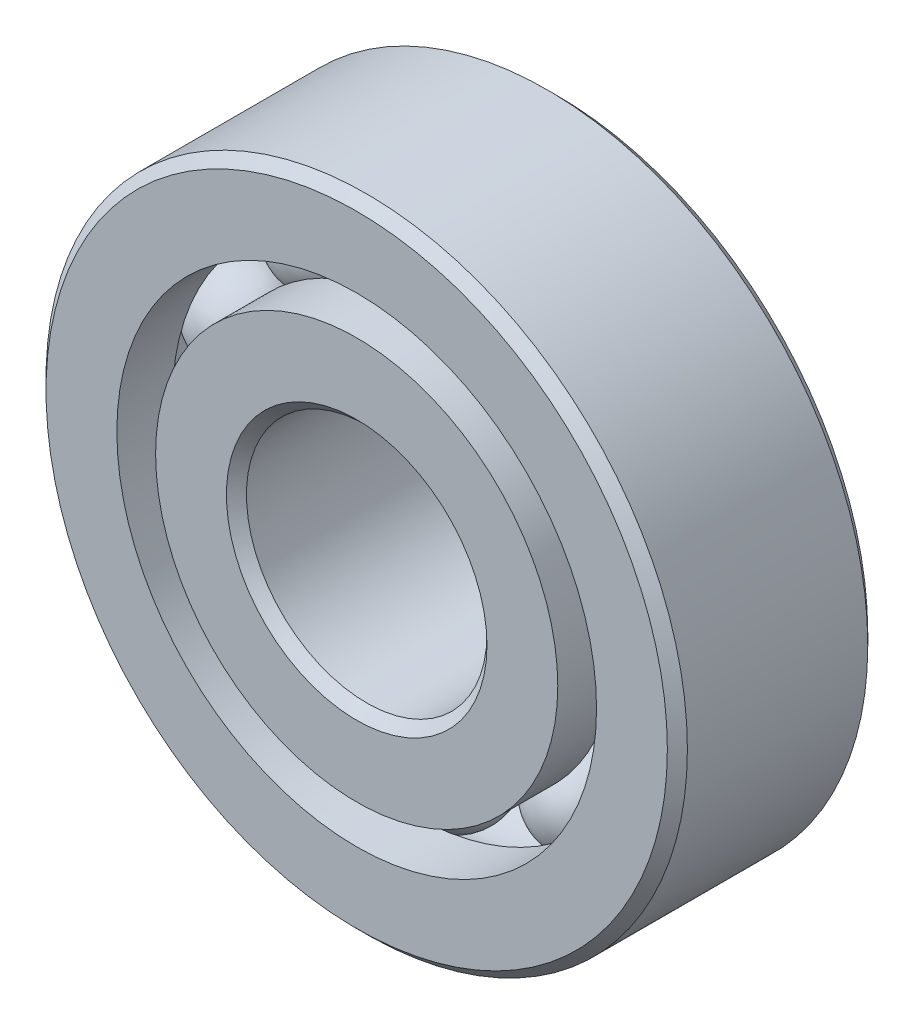
from build123d import *

# Parameters (mm, degrees)
CIRPATTERN1_COUNT = 10


with BuildPart() as part:
    # Sketch1 → Revolve1 (revolve)
    with BuildSketch(Plane(origin=(0, 0, 0), x_dir=(0, 0, -1), z_dir=(1, 0, 0))):
        with BuildLine():
            Line((1.7859375, 6.35), (-1.7859375, 6.35))
            Line((-1.7859375, 6.35), (-1.984375, 6.1515625))
            Line((-1.984375, 6.1515625), (-1.984375, 4.749416209))
            Line((-1.984375, 4.749416209), (-0.881944444, 4.749416209))
            ThreePointArc((-0.881944444, 4.749416209), (0, 5.327457467), (0.881944444, 4.749416209))
            Line((0.881944444, 4.749416209), (1.984375, 4.749416209))
            Line((1.984375, 4.749416209), (1.984375, 6.1515625))
            Line((1.984375, 6.1515625), (1.7859375, 6.35))
        make_face()
    revolve(axis=Axis((0, 0, 1.984375), (0, 0, -1)))


with BuildPart() as body_2:
    # Sketch3 → Revolve3 (revolve)
    with BuildSketch(Plane(origin=(0, 0, 0), x_dir=(0, 0, -1), z_dir=(1, 0, 0))):
        with BuildLine():
            Line((-1.984375, 3.981833791), (-0.881944444, 3.981833791))
            ThreePointArc((-0.881944444, 3.981833791), (0, 3.403792533), (0.881944444, 3.981833791))
            Line((0.881944444, 3.981833791), (1.984375, 3.981833791))
            Line((1.984375, 3.981833791), (1.984375, 2.5796875))
            Line((1.984375, 2.5796875), (1.7859375, 2.38125))
            Line((1.7859375, 2.38125), (-1.7859375, 2.38125))
            Line((-1.7859375, 2.38125), (-1.984375, 2.5796875))
            Line((-1.984375, 2.5796875), (-1.984375, 3.981833791))
        make_face()
    revolve(axis=Axis((0, 0, 1.984375), (0, 0, -1)))


with BuildPart() as body_3:
    # Sketch4 → Revolve4 (revolve)
    with BuildSketch(Plane(origin=(0, 0, 0), x_dir=(0, 0, -1), z_dir=(1, 0, 0))):
        with BuildLine():
            Line((-0.961832467, 4.365625), (0.961832467, 4.365625))
            ThreePointArc((0.961832467, 4.365625), (0, 5.327457467), (-0.961832467, 4.365625))
        make_face()
    revolve(axis=Axis((0, 4.365625, 0.961832467), (0, 0, -1)))


with BuildPart() as cirpattern1_1:
    # CirPattern1: pattern copy
    add(body_3.part.rotate(Axis((0, 0, 0), (0, 0, 1)), 1 * 360 / CIRPATTERN1_COUNT))


with BuildPart() as cirpattern1_2:
    # CirPattern1: pattern copy
    add(body_3.part.rotate(Axis((0, 0, 0), (0, 0, 1)), 2 * 360 / CIRPATTERN1_COUNT))


with BuildPart() as cirpattern1_3:
    # CirPattern1: pattern copy
    add(body_3.part.rotate(Axis((0, 0, 0), (0, 0, 1)), 3 * 360 / CIRPATTERN1_COUNT))


with BuildPart() as cirpattern1_4:
    # CirPattern1: pattern copy
    add(body_3.part.rotate(Axis((0, 0, 0), (0, 0, 1)), 4 * 360 / CIRPATTERN1_COUNT))


with BuildPart() as cirpattern1_5:
    # CirPattern1: pattern copy
    add(body_3.part.rotate(Axis((0, 0, 0), (0, 0, 1)), 5 * 360 / CIRPATTERN1_COUNT))


with BuildPart() as cirpattern1_6:
    # CirPattern1: pattern copy
    add(body_3.part.rotate(Axis((0, 0, 0), (0, 0, 1)), 6 * 360 / CIRPATTERN1_COUNT))


with BuildPart() as cirpattern1_7:
    # CirPattern1: pattern copy
    add(body_3.part.rotate(Axis((0, 0, 0), (0, 0, 1)), 7 * 360 / CIRPATTERN1_COUNT))


with BuildPart() as cirpattern1_8:
    # CirPattern1: pattern copy
    add(body_3.part.rotate(Axis((0, 0, 0), (0, 0, 1)), 8 * 360 / CIRPATTERN1_COUNT))


with BuildPart() as cirpattern1_9:
    # CirPattern1: pattern copy
    add(body_3.part.rotate(Axis((0, 0, 0), (0, 0, 1)), 9 * 360 / CIRPATTERN1_COUNT))


solid = Compound([part.part, body_2.part, body_3.part, cirpattern1_1.part, cirpattern1_2.part, cirpattern1_3.part, cirpattern1_4.part, cirpattern1_5.part, cirpattern1_6.part, cirpattern1_7.part, cirpattern1_8.part, cirpattern1_9.part])
